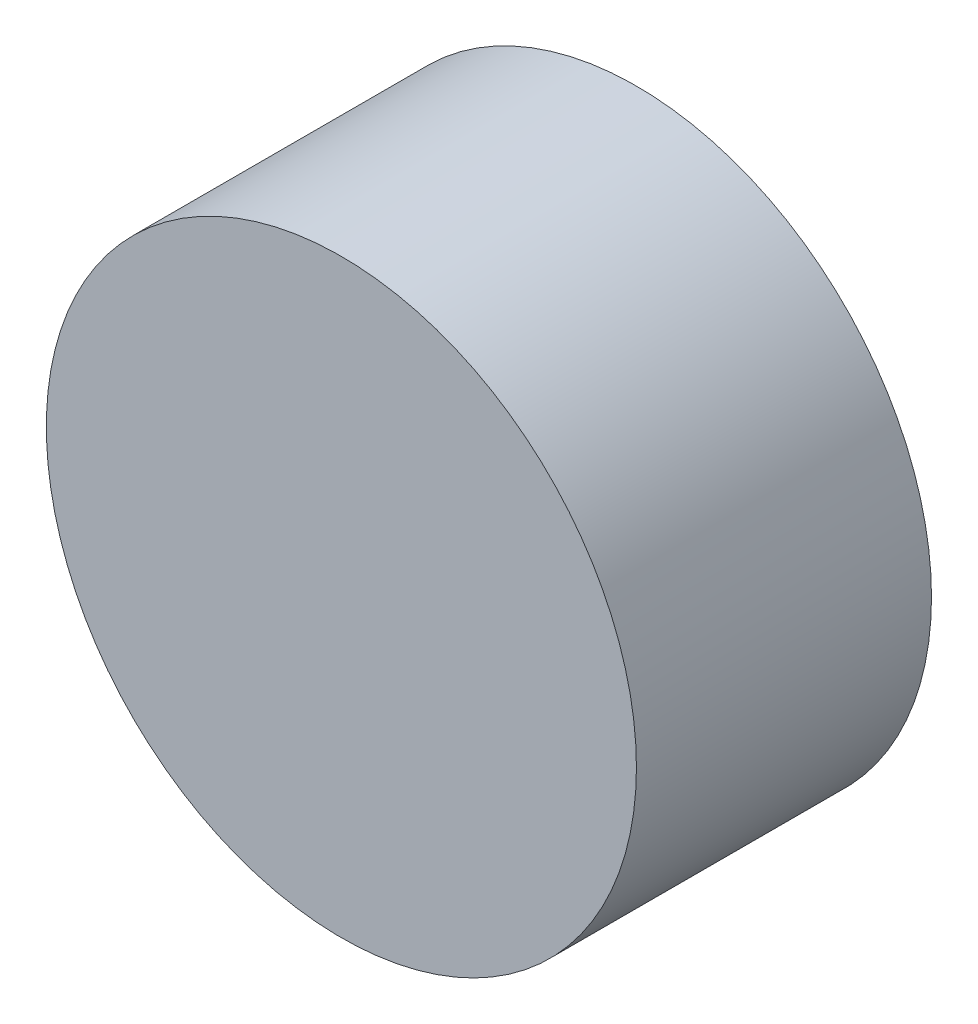
from build123d import *

# Parameters (mm, degrees)
SKIZZE1_R                       = 50
AUFSATZ_LINEAR_AUSTRAGEN1_DEPTH = 50


with BuildPart() as part:
    # Skizze1 → Aufsatz-Linear austragen1 (new body)
    with BuildSketch(Plane.XY):
        Circle(SKIZZE1_R)
    extrude(amount=AUFSATZ_LINEAR_AUSTRAGEN1_DEPTH)


solid = part.part
